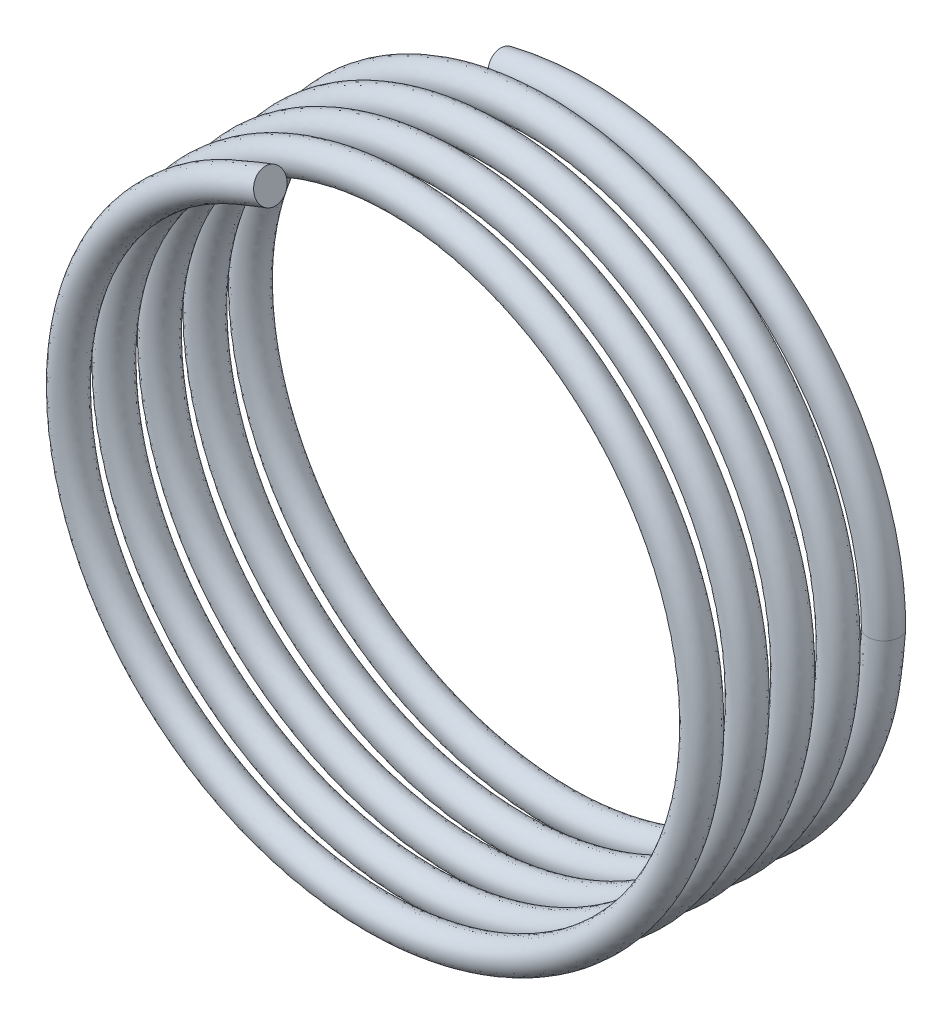
from build123d import *

# Parameters (mm, degrees)
BASE_SWEEP_PITCH  = 1.729361702
BASE_SWEEP_HEIGHT = 8.128
BASE_SWEEP_RADIUS = 11.6078
SKETCH2_R         = 0.5969
SKETCH4_R         = 0.5969


with BuildPart() as part:
    # Base-Sweep: sweep along a helix
    with BuildLine() as base_sweep_path:
        Helix(BASE_SWEEP_PITCH, BASE_SWEEP_HEIGHT, BASE_SWEEP_RADIUS, center=(0, 0, 0), direction=(0, 0, 1), lefthand=True)
    # Sketch2 → Base-Sweep (sweep)
    with BuildSketch(Plane(origin=(-3.587007467, 11.03967383, 8.128), x_dir=(-0.309838275, 0.948002581, 0.07274166), z_dir=(0.950789274, 0.308930162, 0.023704675))):
        Circle(SKETCH2_R)
    sweep(path=base_sweep_path.line, is_frenet=True)

    # Boss-Sweep1: sweep along a path in Sketch3
    with BuildLine(Plane.XY) as boss_sweep1_path:
        ThreePointArc((11.6078, 0), (7.146475273, 9.147071226), (-2.80818098, 11.262998731))
    # Sketch4 → Boss-Sweep1 (sweep)
    with BuildSketch(Plane(origin=(0, 0, 0), x_dir=(-1, 0, 0), z_dir=(0, 0.999719005, -0.023704675))):
        with Locations((-11.6078, 0)):
            Circle(SKETCH4_R)
    sweep(path=boss_sweep1_path.line)


solid = part.part
